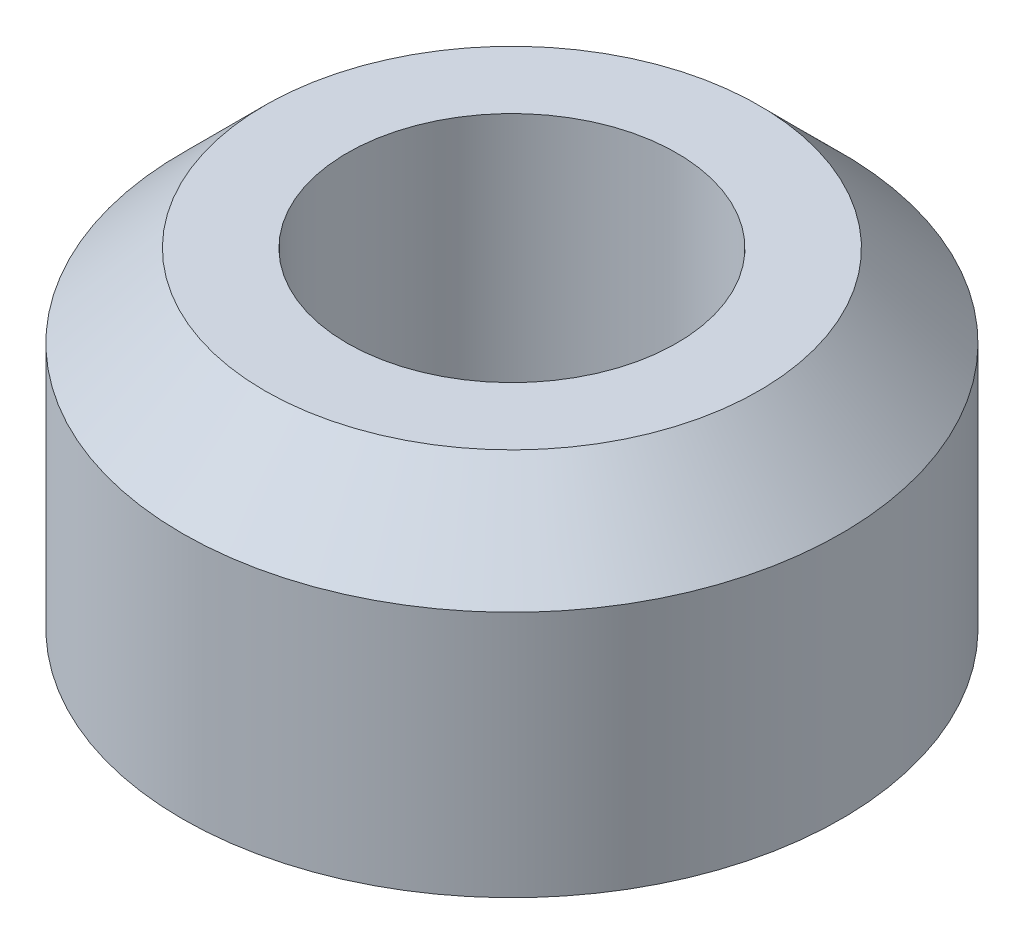
from build123d import *


with BuildPart() as part:
    # Sketch1 → Revolve1 (revolve)
    with BuildSketch(Plane.XY):
        Polygon((3.175, 0), (6.35, 0), (6.35, 4.7625), (4.7625, 6.35), (3.175, 6.35), align=None)
    revolve(axis=Axis((0, 6.35, 0), (0, -1, 0)))


solid = part.part
